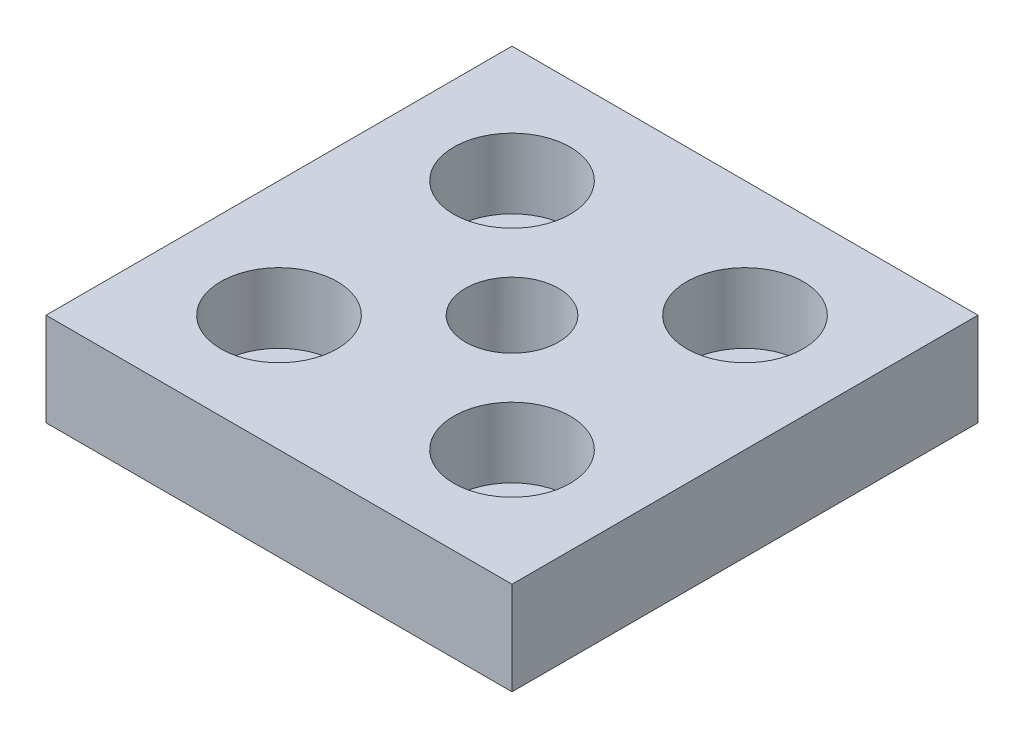
from build123d import *

# Parameters (mm, degrees)
SKETCH_1_W             = 60
SKETCH_1_H             = 60
EXTRUDE_1_DEPTH        = 12
HOLE_WIZARD_M141_D     = 12
HOLE_WIZARD_M141_DEPTH = 12
SKETCH_12_R            = 4.5
CUT_EXTRUDE_1_DEPTH    = 13
SKETCH_13_R            = 7.5
CUT_EXTRUDE_2_DEPTH    = 9


with BuildPart() as part:
    # Эскиз1 → Бобышка-Вытянуть1 (new body)
    with BuildSketch(Plane(origin=(0, 0, 0), x_dir=(1, 0, 0), z_dir=(0, 1, 0))):
        Rectangle(SKETCH_1_W, SKETCH_1_H)
    extrude(amount=EXTRUDE_1_DEPTH)

    # Отверстие обработанное метчиком M141
    with Locations(Plane(origin=(0, 12, 0), x_dir=(1, 0, 0), z_dir=(0, 1, 0))):
        with Locations((0, 0)):
            Hole(HOLE_WIZARD_M141_D / 2, depth=HOLE_WIZARD_M141_DEPTH)

    # Эскиз12 → Вырез-Вытянуть1 (cut, through all)
    with BuildSketch(Plane(origin=(0, 12, 0), x_dir=(1, 0, 0), z_dir=(0, 1, 0))):
        with Locations(Location((-15, 15, 0), (0, 0, 270))):  # turned: the seam where the file's is
            Circle(SKETCH_12_R)
        with Locations(Location((15, 15, 0), (0, 0, 270))):  # turned: the seam where the file's is
            Circle(SKETCH_12_R)
        with Locations(Location((15, -15, 0), (0, 0, 270))):  # turned: the seam where the file's is
            Circle(SKETCH_12_R)
        with Locations(Location((-15, -15, 0), (0, 0, 270))):  # turned: the seam where the file's is
            Circle(SKETCH_12_R)
    extrude(amount=-CUT_EXTRUDE_1_DEPTH, mode=Mode.SUBTRACT)

    # Эскиз13 → Вырез-Вытянуть2 (cut)
    with BuildSketch(Plane(origin=(0, 12, 0), x_dir=(1, 0, 0), z_dir=(0, 1, 0))):
        with Locations(Location((-15, 15, 0), (0, 0, 270))):  # turned: the seam where the file's is
            Circle(SKETCH_13_R)
        with Locations(Location((15, 15, 0), (0, 0, 270))):  # turned: the seam where the file's is
            Circle(SKETCH_13_R)
        with Locations(Location((15, -15, 0), (0, 0, 270))):  # turned: the seam where the file's is
            Circle(SKETCH_13_R)
        with Locations(Location((-15, -15, 0), (0, 0, 270))):  # turned: the seam where the file's is
            Circle(SKETCH_13_R)
    extrude(amount=-CUT_EXTRUDE_2_DEPTH, mode=Mode.SUBTRACT)


solid = part.part
